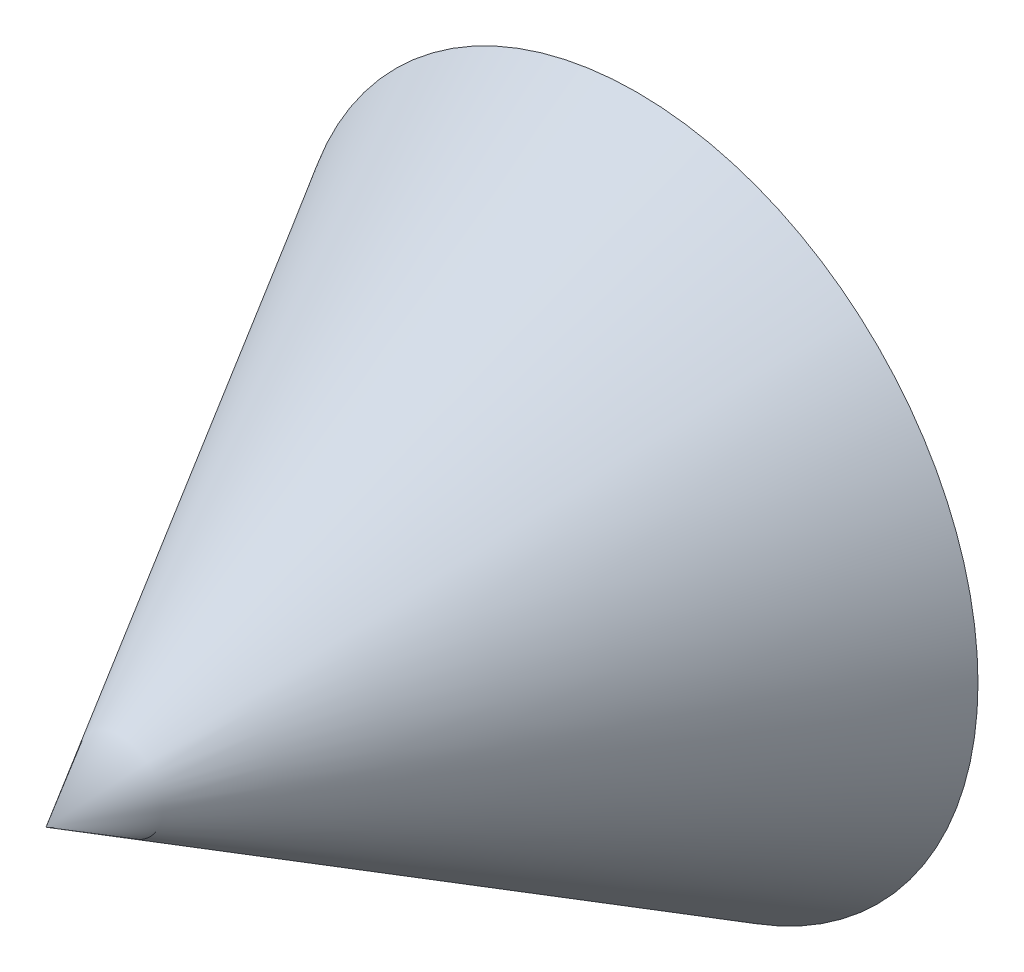
from build123d import *


with BuildPart() as part:
    # Sketch1 → Revolve1 (revolve)
    with BuildSketch(Plane(origin=(0, 0, 0), x_dir=(1, 0, 0), z_dir=(0, 1, 0))):
        Polygon((0, 0), (0, 7.55), (-4.35635, 7.55), align=None)
    revolve(axis=Axis((0, 0, 0), (0, 0, -1)))


solid = part.part
